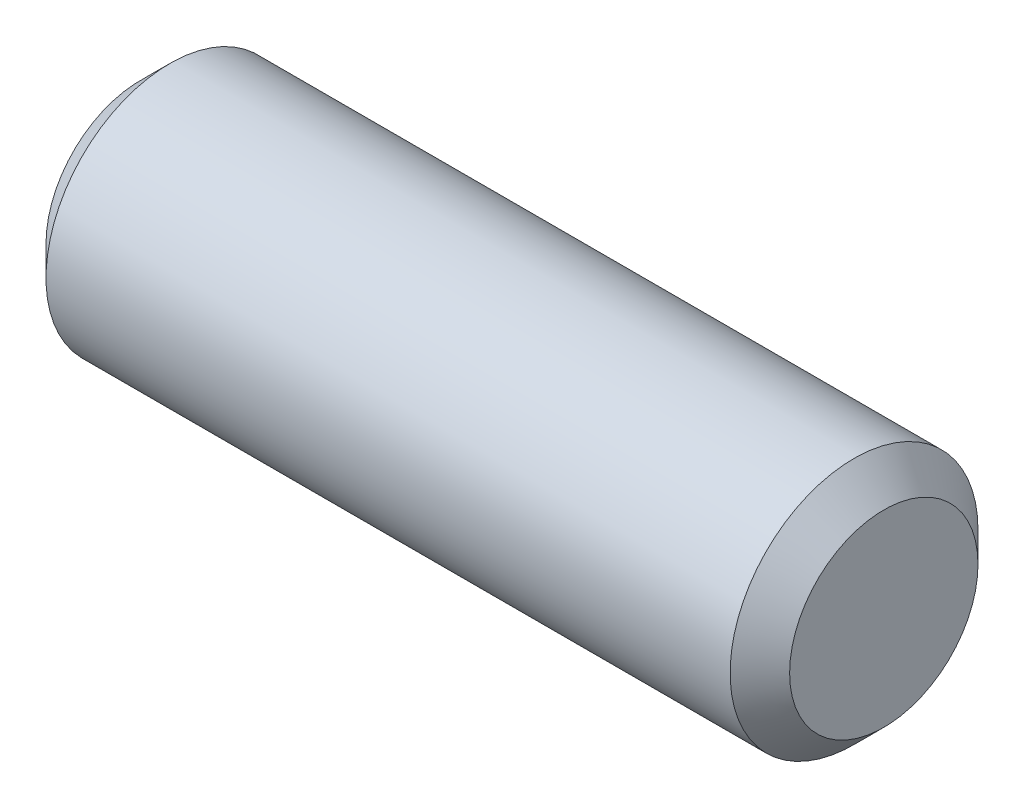
from build123d import *

# Parameters (mm, degrees)
SKETCH2_R           = 6.35
BOSS_EXTRUDE1_DEPTH = 38.1
CHAMFER1_SIZE       = 1.524
CHAMFER2_SIZE       = 1.524


with BuildPart() as part:
    # Sketch2 → Boss-Extrude1 (new body)
    with BuildSketch(Plane(origin=(0, 0, 0), x_dir=(0, 0, -1), z_dir=(1, 0, 0))):
        Circle(SKETCH2_R)
    extrude(amount=BOSS_EXTRUDE1_DEPTH)

    # Chamfer1
    chamfer1_edges = [part.edges().sort_by_distance(p)[0] for p in [
        (38.1, 0, 6.35),
    ]]
    chamfer(chamfer1_edges, length=CHAMFER1_SIZE)

    # Chamfer2
    chamfer2_edges = [part.edges().sort_by_distance(p)[0] for p in [
        (0, 0, 6.35),
    ]]
    chamfer(chamfer2_edges, length=CHAMFER2_SIZE)


solid = part.part
